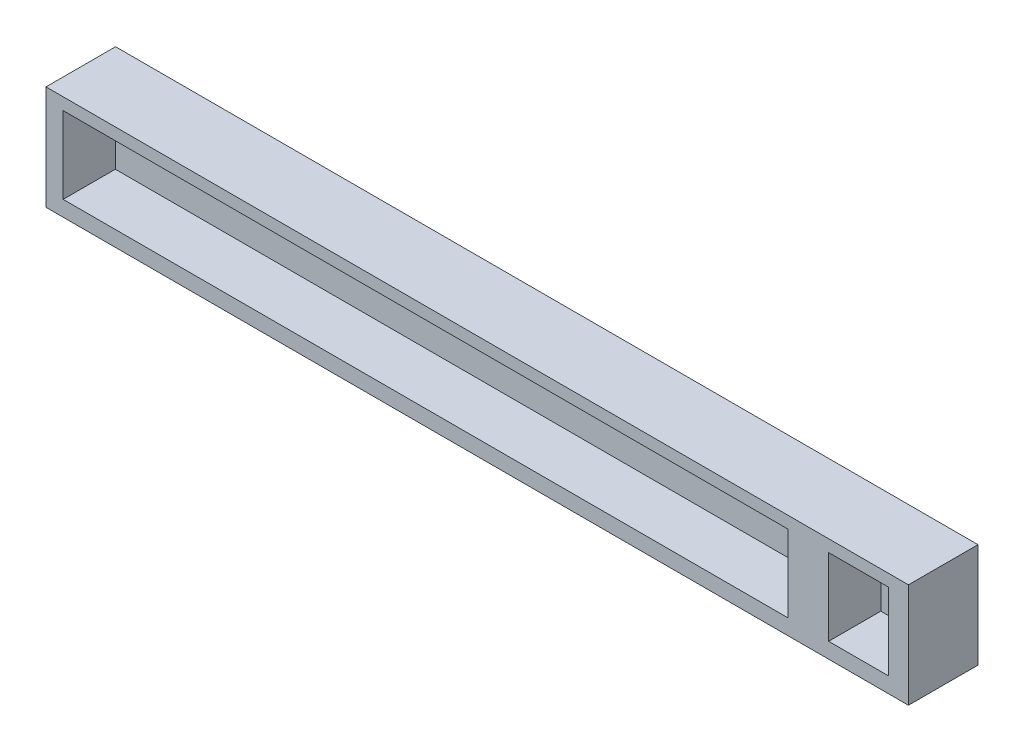
from build123d import *

# Parameters (mm, degrees)
SKIZZE3_W                       = 248
SKIZZE3_H                       = 30
AUFSATZ_LINEAR_AUSTRAGEN2_DEPTH = 20
SKIZZE4_W                       = 17.223807704
SKIZZE4_H                       = 22.103886552
SKIZZE4_W_2                     = 208.49303605
SCHNITT_LINEAR_AUSTRAGEN1_DEPTH = 15


with BuildPart() as part:
    # Skizze3 → Aufsatz-Linear austragen2 (new body)
    with BuildSketch(Plane.XY):
        with Locations((124, 15)):
            Rectangle(SKIZZE3_W, SKIZZE3_H)
    extrude(amount=AUFSATZ_LINEAR_AUSTRAGEN2_DEPTH)

    # Skizze4 → Schnitt-Linear austragen1 (cut)
    with BuildSketch(Plane.XY.offset(20)):
        with Locations((233.658670334, 15.507719538)):
            Rectangle(SKIZZE4_W, SKIZZE4_H)
        with Locations((109.18391288, 15.507719538)):
            Rectangle(SKIZZE4_W_2, SKIZZE4_H)
    extrude(amount=-SCHNITT_LINEAR_AUSTRAGEN1_DEPTH, mode=Mode.SUBTRACT)


solid = part.part
